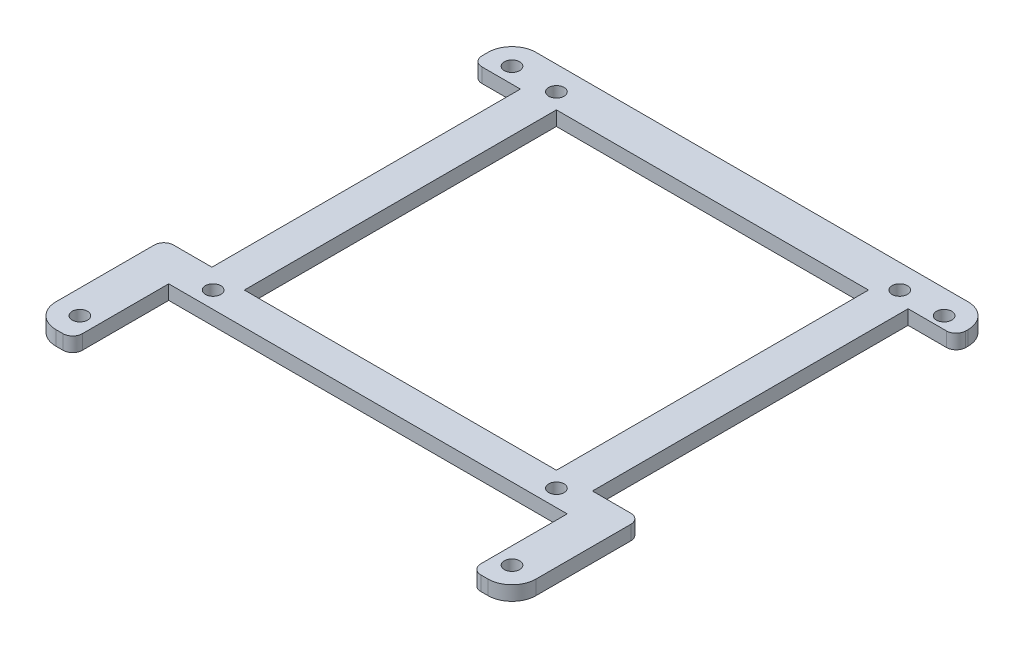
from build123d import *

# Parameters (mm, degrees)
SKETCH1_R           = 1.6
SKETCH1_W           = 65
SKETCH1_H           = 65
BOSS_EXTRUDE1_DEPTH = 3
FILLET1_R           = 2
FILLET2_R           = 5


with BuildPart() as part:
    # Sketch1 → Boss-Extrude1 (new body)
    with BuildSketch(Plane(origin=(0, 0, 0), x_dir=(1, 0, 0), z_dir=(0, 1, 0))):
        Polygon((-50, 50), (-50, 41.75), (-40, 41.75), (-40, -22.5), (-50, -22.5), (-50, -50), (-41.5, -50), (-41.5, -30), (41.5, -30), (41.5, -50), (50, -50), (50, -23.25), (40, -23.25), (40, 42.5), (50, 42.5), (50, 50), align=None)
        with Locations((-45, -45)):
            Circle(SKETCH1_R, mode=Mode.SUBTRACT)
        with Locations((-35.75, -26.5)):
            Circle(SKETCH1_R, mode=Mode.SUBTRACT)
        with Locations((45, -45)):
            Circle(SKETCH1_R, mode=Mode.SUBTRACT)
        with Locations((35.75, -26.5)):
            Circle(SKETCH1_R, mode=Mode.SUBTRACT)
        with Locations((0, 9.25)):
            Rectangle(SKETCH1_W, SKETCH1_H, mode=Mode.SUBTRACT)
        with Locations((-45, 45)):
            Circle(SKETCH1_R, mode=Mode.SUBTRACT)
        with Locations((-35.75, 45)):
            Circle(SKETCH1_R, mode=Mode.SUBTRACT)
        with Locations((35.75, 45)):
            Circle(SKETCH1_R, mode=Mode.SUBTRACT)
        with Locations((45, 45)):
            Circle(SKETCH1_R, mode=Mode.SUBTRACT)
    extrude(amount=BOSS_EXTRUDE1_DEPTH)

    # Fillet1
    fillet1_edges = [part.edges().sort_by_distance(p)[0] for p in [
        (50, 1.5, 23.25),
        (41.5, 1.5, 50),
        (-41.5, 1.5, 50),
        (-50, 1.5, 22.5),
        (-50, 1.5, -41.75),
        (50, 1.5, -42.5),
    ]]
    fillet(fillet1_edges, radius=FILLET1_R)

    # Fillet2
    fillet2_edges = [part.edges().sort_by_distance(p)[0] for p in [
        (50, 1.5, 50),
        (-50, 1.5, 50),
        (-50, 1.5, -50),
        (50, 1.5, -50),
    ]]
    fillet(fillet2_edges, radius=FILLET2_R)


solid = part.part
